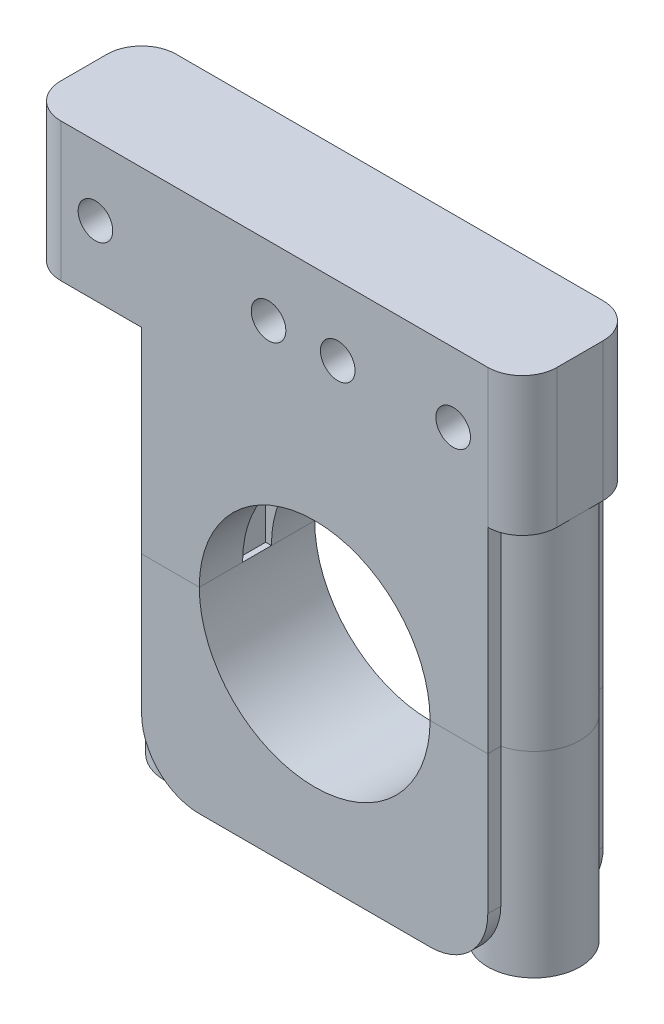
from build123d import *

# Parameters (mm, degrees)
SKETCH1_R           = 10.000000000000004
SKETCH1_R_2         = 1.5000000000000007
SKETCH1_R_3         = 1.5000000000000027
SKETCH1_R_4         = 1.5000000000000024
BOSS_EXTRUDE1_DEPTH = 10
CUT_EXTRUDE1_DEPTH  = 34
CUT_EXTRUDE3_START  = 20
SKETCH3_W           = 0.5
SKETCH3_H           = 2.499999999999996
CUT_EXTRUDE3_DEPTH  = 10
CUT_EXTRUDE4_START  = 20
SKETCH3_3_W         = 0.5
SKETCH3_3_H         = 2.499999999999996
CUT_EXTRUDE4_DEPTH  = 1
FILLET1_R           = 5
CHAMFER1_SIZE       = 1.5
BOSS_EXTRUDE2_REACH = 37.567
SKETCH5_W           = 36
SKETCH5_H           = 12.000000000000004
SKETCH5_R           = 1.5000000000000024
SKETCH5_R_2         = 1.500000000000002
SKETCH5_R_3         = 1.5
CUT_EXTRUDE6_DEPTH  = 12
BOSS_EXTRUDE3_START = -10
SKETCH7_R           = 1.5000000000000215
BOSS_EXTRUDE3_DEPTH = 10
CUT_EXTRUDE7_START  = -10
SKETCH8_R           = 1.5000000000000042
SKETCH8_W           = 26.999999999999982
SKETCH8_H           = 12.000000000000004
CUT_EXTRUDE7_DEPTH  = 10
FILLET2_R           = 3


with BuildPart() as part:
    # Sketch1 → Boss-Extrude1 (new body)
    with BuildSketch(Plane.XY):
        with BuildLine():
            ThreePointArc((7.0000000000000355, 26.31662479035534), (3.3722813232688944, 28.84096258931757), (-1.0000000000002711, 28.196152422706483))
            ThreePointArc((-1.0000000000002185, 28.196152422706756), (-7.000000000000114, 28.19615242270657), (-10.000000000000007, 23))
            Line((-10.000000000000005, 23), (-10.000000000000005, 17))
            Line((-10.000000000000004, 17), (-18.000000000000004, 17))
            Line((-18.000000000000004, 17), (-18.000000000000004, -17))
            Line((-18.000000000000004, -17), (17.999999999999996, -17))
            Line((17.999999999999996, -17), (17.999999999999996, 23))
            ThreePointArc((17.999999999999996, 23), (13.73205080756885, 28.744562646538036), (6.999999999999968, 26.316624790355363))
        make_face()
        Circle(SKETCH1_R, mode=Mode.SUBTRACT)
        with Locations((-4.0000000000000036, 23)):
            Circle(SKETCH1_R_2, mode=Mode.SUBTRACT)
        with Locations((1.9999999999999956, 23)):
            Circle(SKETCH1_R_3, mode=Mode.SUBTRACT)
        with Locations((11.999999999999995, 23)):
            Circle(SKETCH1_R_4, mode=Mode.SUBTRACT)
    extrude(amount=BOSS_EXTRUDE1_DEPTH)

    # Sketch2 → Cut-Extrude1 (cut)
    with BuildSketch(Plane.XZ.offset(17)):
        with BuildLine():
            Line((-14.000000000000002, 6.999999999999998), (-14.000000000000002, 2.9999999999999996))
            ThreePointArc((-13.999999999999972, 2.9999999999999996), (-12.585786437626895, 3.5857864376269153), (-12.000000000000002, 4.999999999999998))
            ThreePointArc((-12.000000000000002, 4.999999999999999), (-12.585786437626897, 6.414213562373083), (-13.999999999999972, 6.999999999999998))
        make_face()
        with BuildLine():
            ThreePointArc((-15, 3.267949192431122), (-14.517638090205029, 3.068148347421859), (-13.999999999999972, 2.9999999999999996))
            Line((-14.000000000000002, 2.9999999999999996), (-14.000000000000002, 6.999999999999998))
            ThreePointArc((-13.999999999999972, 6.999999999999998), (-14.517638090205029, 6.931851652578139), (-15.000000000000002, 6.732050807568876))
            Line((-15.000000000000002, 6.732050807568876), (-15.000000000000002, 3.2679491924311215))
        make_face()
        with BuildLine():
            ThreePointArc((-15.000000000000002, 6.732050807568876), (-16, 4.999999999999998), (-15, 3.267949192431122))
            Line((-15.000000000000002, 3.2679491924311215), (-15.000000000000002, 6.732050807568876))
        make_face()
        with BuildLine():
            Line((14.999999999999996, 6.732050807568884), (15, 3.2679491924311357))
            ThreePointArc((15.000000000000002, 3.267949192431135), (15.732050807568875, 4.000000000000011), (15.999999999999996, 5.000000000000009))
            ThreePointArc((15.999999999999996, 5.00000000000001), (15.732050807568875, 6.000000000000008), (15, 6.732050807568885))
        make_face()
        with BuildLine():
            Line((13.999999999999996, 7.000000000000009), (14, 3.0000000000000107))
            ThreePointArc((14.000000000000028, 3.0000000000000107), (14.517638090205056, 3.0681483474218787), (15.000000000000002, 3.267949192431135))
            Line((15, 3.2679491924311357), (14.999999999999996, 6.732050807568884))
            ThreePointArc((15, 6.732050807568885), (14.517638090205056, 6.931851652578141), (14.000000000000027, 7.000000000000009))
        make_face()
        with BuildLine():
            ThreePointArc((14.000000000000027, 7.000000000000009), (12, 5.000000000000009), (14.000000000000028, 3.0000000000000107))
            Line((14, 3.0000000000000107), (13.999999999999996, 7.000000000000009))
        make_face()
        with BuildLine():
            Line((14.999999999999995, 10.00000000000001), (14.999999999999995, 8.87298334620741))
            ThreePointArc((15.000000000000027, 8.872983346207418), (17.162277660168385, 7.449489742783175), (17.999999999999996, 5.00000000000001))
            Line((17.999999999999996, 5.00000000000001), (17.999999999999996, 10))
            Line((17.999999999999996, 10), (14.999999999999995, 10))
        make_face()
        with BuildLine():
            Line((15.000000000000002, 1.1270166537926105), (15.000000000000002, 1.066e-14))
            Line((15.000000000000004, 0), (17.999999999999996, 0))
            Line((17.999999999999996, 0), (17.999999999999996, 5.00000000000001))
            ThreePointArc((17.999999999999996, 5.000000000000009), (17.162277660168385, 2.5505102572168443), (15.000000000000032, 1.1270166537926025))
        make_face()
        with BuildLine():
            Line((-18.000000000000004, 10), (-18.000000000000004, 5))
            ThreePointArc((-18.000000000000004, 5), (-17.16227766016838, 7.449489742783178), (-15.000000000000004, 8.872983346207416))
            Line((-15.000000000000002, 8.872983346207416), (-15.000000000000002, 10))
            Line((-15.000000000000004, 10), (-18.000000000000004, 10))
        make_face()
        with BuildLine():
            Line((-18.000000000000004, 0), (-15.000000000000002, 0))
            Line((-15.000000000000002, 0), (-15.000000000000002, 1.127016653792582))
            ThreePointArc((-15.000000000000004, 1.1270166537925816), (-17.16227766016838, 2.5505102572168212), (-18.000000000000004, 5))
            Line((-18.000000000000004, 5), (-18.000000000000004, 0))
        make_face()
    extrude(amount=-CUT_EXTRUDE1_DEPTH, mode=Mode.SUBTRACT)

    # Sketch3 → Cut-Extrude3 (cut)
    with BuildSketch(Plane(origin=(0, -10.000000000000002, 0), x_dir=(1, 0, 0), z_dir=(0, 1, 0)).offset(CUT_EXTRUDE3_START)):
        Polygon((10.000000000000002, -6.2499999999999964), (10.000000000000002, -3.7500000000000004), (-8.662112306558027, -3.7500000000000004), (-8.662112306558027, -6.250000000000001), align=None)
        Polygon((-8.662112306558027, -3.7500000000000004), (-10.000000000000002, -3.7500000000000004), (-10, -6.250000000000003), (-8.662112306558027, -6.250000000000002), align=None)
        Polygon((-10, -6.250000000000003), (-10.000000000000002, -3.7500000000000004), (-10.5, -3.7500000000000004), (-10.5, -6.250000000000002), align=None)
        with Locations((10.250000000000002, -4.999999999999998)):
            Rectangle(SKETCH3_W, SKETCH3_H)
    extrude(amount=-CUT_EXTRUDE3_DEPTH, mode=Mode.SUBTRACT)

    # Sketch3_3 → Cut-Extrude4 (cut)
    with BuildSketch(Plane(origin=(0, -10.000000000000002, 0), x_dir=(1, 0, 0), z_dir=(0, 1, 0)).offset(CUT_EXTRUDE4_START)):
        Polygon((10.000000000000002, -6.2499999999999964), (10.000000000000002, -3.7500000000000004), (-8.662112306558027, -3.7500000000000004), (-8.662112306558027, -6.250000000000001), align=None)
        Polygon((-8.662112306558027, -3.7500000000000004), (-10.000000000000002, -3.7500000000000004), (-10, -6.250000000000003), (-8.662112306558027, -6.250000000000002), align=None)
        Polygon((-10, -6.250000000000003), (-10.000000000000002, -3.7500000000000004), (-10.5, -3.7500000000000004), (-10.5, -6.250000000000002), align=None)
        with Locations((10.250000000000002, -4.999999999999998)):
            Rectangle(SKETCH3_3_W, SKETCH3_3_H)
    extrude(amount=CUT_EXTRUDE4_DEPTH, mode=Mode.SUBTRACT)

    # Fillet1
    fillet1_edges = [part.edges().sort_by_distance(p)[0] for p in [
        (-15.000000000000002, -17, 0.563508326896291),
        (14.999999999999995, -17, 9.43649167310371),
        (15.000000000000002, -17, 0.5635083268963106),
        (-15.000000000000002, -17, 9.436491673103708),
    ]]
    fillet(fillet1_edges, radius=FILLET1_R)

    # Chamfer1
    chamfer1_edges = [part.edges().sort_by_distance(p)[0] for p in [
        (13.999999999999972, -17, 7.00000000000001),
        (-13.000000000000005, -17, 3.2679491924311277),
    ]]
    chamfer(chamfer1_edges, length=CHAMFER1_SIZE)


with BuildPart() as body_2:
    # Split1: the piece on the far side of the plane
    add(part.part)
    split(bisect_by=Plane.ZX, keep=Keep.BOTTOM)


with BuildPart() as part_1:
    add(part.part)

    # Split1
    split(bisect_by=Plane.ZX, keep=Keep.TOP)

    # Boss-Extrude2: up to this face of the body (flat: up to its plane)
    boss_extrude2_end = Plane(part_1.part.faces().sort_by_distance((1.800705517, 15.88757201, 10))[0])
    # Sketch5 → Boss-Extrude2 (add, up to the picked face)
    with BuildSketch(Plane(origin=(0, 0, 0), x_dir=(-1, 0, 0), z_dir=(0, 0, -1)), mode=Mode.PRIVATE) as boss_extrude2_sk1:
        with Locations((3.55e-15, 23)):
            Rectangle(SKETCH5_W, SKETCH5_H)
        with Locations(Location((-11.999999999999995, 23, 0), (0, 0, 180))):
            Circle(SKETCH5_R, mode=Mode.SUBTRACT)
        with Locations(Location((-1.999999999999995, 23, 0), (0, 0, 180))):
            Circle(SKETCH5_R_2, mode=Mode.SUBTRACT)
        with Locations(Location((4.000000000000005, 23, 0), (0, 0, 180))):
            Circle(SKETCH5_R_3, mode=Mode.SUBTRACT)
    boss_extrude2_tool1 = split(extrude(boss_extrude2_sk1.sketch, amount=-BOSS_EXTRUDE2_REACH, mode=Mode.PRIVATE), bisect_by=boss_extrude2_end, keep=Keep.BOTH, mode=Mode.PRIVATE)
    add(boss_extrude2_tool1.solids().sort_by(Axis((-0.172071, 23, 0), (0, 0, 1)))[0])

    # Sketch6 → Cut-Extrude6 (cut)
    with BuildSketch(Plane.XZ.offset(-17)):
        with BuildLine():
            Line((17.999999999999996, 10), (14.999999999999995, 10))
            Line((14.999999999999995, 10), (14.999999999999995, 8.872983346207427))
            ThreePointArc((14.999999999999995, 8.872983346207427), (17.162277660168375, 7.449489742783188), (17.999999999999996, 5.00000000000001))
            Line((17.999999999999996, 5.00000000000001), (17.999999999999996, 10))
        make_face()
        with BuildLine():
            Line((17.999999999999996, 0), (17.999999999999996, 5.00000000000001))
            ThreePointArc((17.999999999999996, 5.00000000000001), (17.162277660168378, 2.550510257216833), (15.000000000000002, 1.1270166537925945))
            Line((15.000000000000002, 1.127016653792595), (15.000000000000002, 0))
            Line((15.000000000000002, 0), (17.999999999999996, 0))
        make_face()
        with BuildLine():
            Line((-15, 10.000000000000002), (-18.000000000000004, 10.000000000000002))
            Line((-18.000000000000004, 10.000000000000002), (-18.000000000000004, 4.999999999999997))
            ThreePointArc((-18.000000000000004, 4.999999999999997), (-17.162277660168385, 7.449489742783179), (-15.000000000000002, 8.872983346207418))
            Line((-15.000000000000002, 8.872983346207418), (-15, 10.000000000000002))
        make_face()
        with BuildLine():
            ThreePointArc((-15.000000000000002, 1.1270166537925816), (-17.16227766016838, 2.55051025721682), (-18.000000000000004, 4.999999999999997))
            Line((-18.000000000000004, 4.999999999999997), (-18.000000000000004, 0))
            Line((-18.000000000000004, 0), (-15, 0))
            Line((-15, 0), (-15.000000000000002, 1.1270166537925814))
        make_face()
    extrude(amount=-CUT_EXTRUDE6_DEPTH, mode=Mode.SUBTRACT)

    # Sketch7 → Boss-Extrude3 (add)
    # profile 1 of 2: a face of its own
    with BuildSketch(Plane.XY.offset(10).offset(BOSS_EXTRUDE3_START)):
        Polygon((-15.000000000000002, 29), (-51.99999999999998, 29.000000000000014), (-51.99999999999998, 17.000000000000014), (-15.000000000000007, 17.000000000000004), align=None)
        with BuildLine():
            ThreePointArc((-18.000000000000018, 21.881966011250086), (-20.500000000000007, 23), (-18.000000000000018, 24.118033988749914))
            Line((-18.000000000000004, 24.118033988749918), (-18.000000000000004, 21.881966011250082))
        make_face(mode=Mode.SUBTRACT)
        with Locations((-45.999999999999986, 23)):
            Circle(SKETCH7_R, mode=Mode.SUBTRACT)
    # profile 2 of 2: a face of its own
    with BuildSketch(Plane.XY.offset(10).offset(BOSS_EXTRUDE3_START)):
        Polygon((18.000000000000004, 29), (14.999999999999996, 29), (14.999999999999995, 17), (18.000000000000004, 17), align=None)
    extrude(amount=BOSS_EXTRUDE3_DEPTH)

    # Sketch8 → Cut-Extrude7 (cut)
    with BuildSketch(Plane.XY.offset(10).offset(CUT_EXTRUDE7_START)):
        with Locations((-19.000000000000004, 23)):
            Circle(SKETCH8_R)
        with Locations((-38.49999999999999, 23.000000000000007)):
            Rectangle(SKETCH8_W, SKETCH8_H)
    extrude(amount=CUT_EXTRUDE7_DEPTH, mode=Mode.SUBTRACT)

    # Fillet2
    fillet2_edges = [part_1.edges().sort_by_distance(p)[0] for p in [
        (18.000000000000004, 23, 0),
        (18.000000000000004, 23, 10),
        (-25, 23.00000000000001, 0),
        (-25, 23.00000000000001, 10),
    ]]
    fillet(fillet2_edges, radius=FILLET2_R)


solid = Compound([body_2.part, part_1.part])
